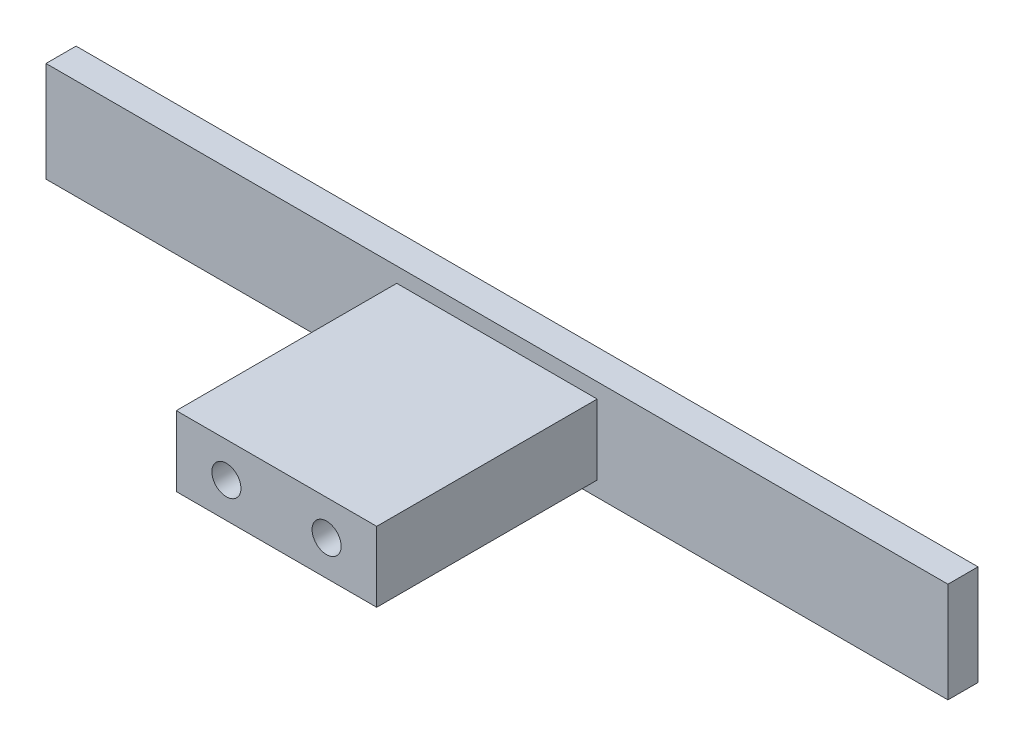
from build123d import *

# Parameters (mm, degrees)
SKETCH_1_W          = 90
SKETCH_1_H          = 10
EXTRUDE_1_DEPTH     = 3
SKETCH_2_W          = 20
SKETCH_2_H          = 7
EXTRUDE_3_DEPTH     = 22
CUT_EXTRUDE_1_DEPTH = 9


with BuildPart() as part:
    # 草图1 → 凸台-拉伸1 (new body)
    with BuildSketch(Plane.XY):
        with Locations((45, 5)):
            Rectangle(SKETCH_1_W, SKETCH_1_H)
    extrude(amount=EXTRUDE_1_DEPTH)

    # 草图2 → 凸台-拉伸3 (add)
    with BuildSketch(Plane.XY.offset(3)):
        with Locations((45, 5)):
            Rectangle(SKETCH_2_W, SKETCH_2_H)
    extrude(amount=EXTRUDE_3_DEPTH)

    # 草图4 → 切除-拉伸1 (cut)
    with BuildSketch(Plane.XY.offset(25)):
        with BuildLine():
            ThreePointArc((48.55, 5), (50, 3.55), (51.45, 5))
            Line((51.45, 5), (50, 5))
            Line((50, 5), (48.55, 5))
        make_face()
        with BuildLine():
            Line((50, 5), (51.45, 5))
            ThreePointArc((51.45, 5), (50, 6.45), (48.55, 5))
            Line((48.55, 5), (50, 5))
        make_face()
        with BuildLine():
            ThreePointArc((48.55, 5), (50, 3.55), (51.45, 5))
            Line((51.45, 5), (50, 5))
            Line((50, 5), (48.55, 5))
        make_face()
        with BuildLine():
            Line((50, 5), (51.45, 5))
            ThreePointArc((51.45, 5), (50, 6.45), (48.55, 5))
            Line((48.55, 5), (50, 5))
        make_face()
        with BuildLine():
            ThreePointArc((38.55, 5), (40, 3.55), (41.45, 5))
            Line((41.45, 5), (40, 5))
            Line((40, 5), (38.55, 5))
        make_face()
        with BuildLine():
            Line((40, 5), (41.45, 5))
            ThreePointArc((41.45, 5), (40, 6.45), (38.55, 5))
            Line((38.55, 5), (40, 5))
        make_face()
        with BuildLine():
            ThreePointArc((38.55, 5), (40, 3.55), (41.45, 5))
            Line((41.45, 5), (40, 5))
            Line((40, 5), (38.55, 5))
        make_face()
        with BuildLine():
            Line((40, 5), (41.45, 5))
            ThreePointArc((41.45, 5), (40, 6.45), (38.55, 5))
            Line((38.55, 5), (40, 5))
        make_face()
    extrude(amount=-CUT_EXTRUDE_1_DEPTH, mode=Mode.SUBTRACT)


solid = part.part
